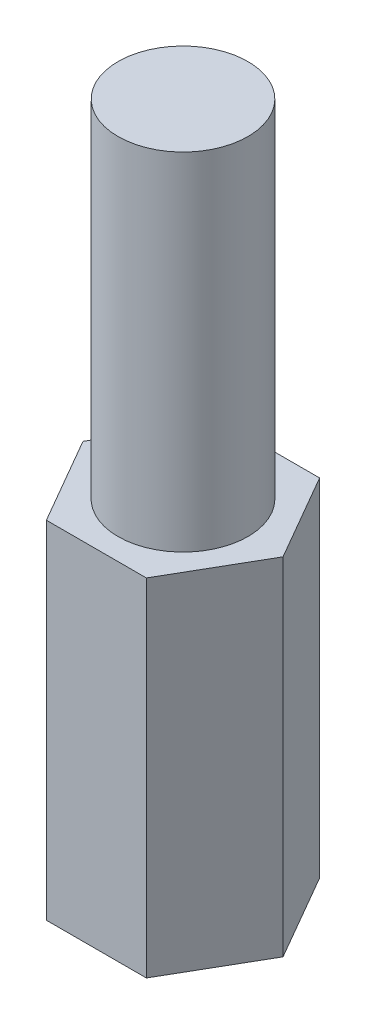
from build123d import *

# Parameters (mm, degrees)
EXTRUDE_1_DEPTH     = 8
SKETCH_2_R          = 1.5
EXTRUDE_2_DEPTH     = 8
SKETCH_3_R          = 1.5
CUT_EXTRUDE_1_DEPTH = 5


with BuildPart() as part:
    # 草图1 → 凸台-拉伸1 (new body)
    with BuildSketch(Plane(origin=(0, 0, 0), x_dir=(1, 0, 0), z_dir=(0, 1, 0))):
        Polygon((-1.154700538, -2), (1.154700538, -2), (2.309401077, 0), (1.154700538, 2), (-1.154700538, 2), (-2.309401077, 0), align=None)
    extrude(amount=EXTRUDE_1_DEPTH)

    # 草图2 → 凸台-拉伸2 (add)
    with BuildSketch(Plane(origin=(0, 8, 0), x_dir=(1, 0, 0), z_dir=(0, 1, 0))):
        Circle(SKETCH_2_R)
    extrude(amount=EXTRUDE_2_DEPTH)

    # 草图3 → 切除-拉伸1 (cut)
    with BuildSketch(Plane.XZ):
        Circle(SKETCH_3_R)
    extrude(amount=-CUT_EXTRUDE_1_DEPTH, mode=Mode.SUBTRACT)


solid = part.part
